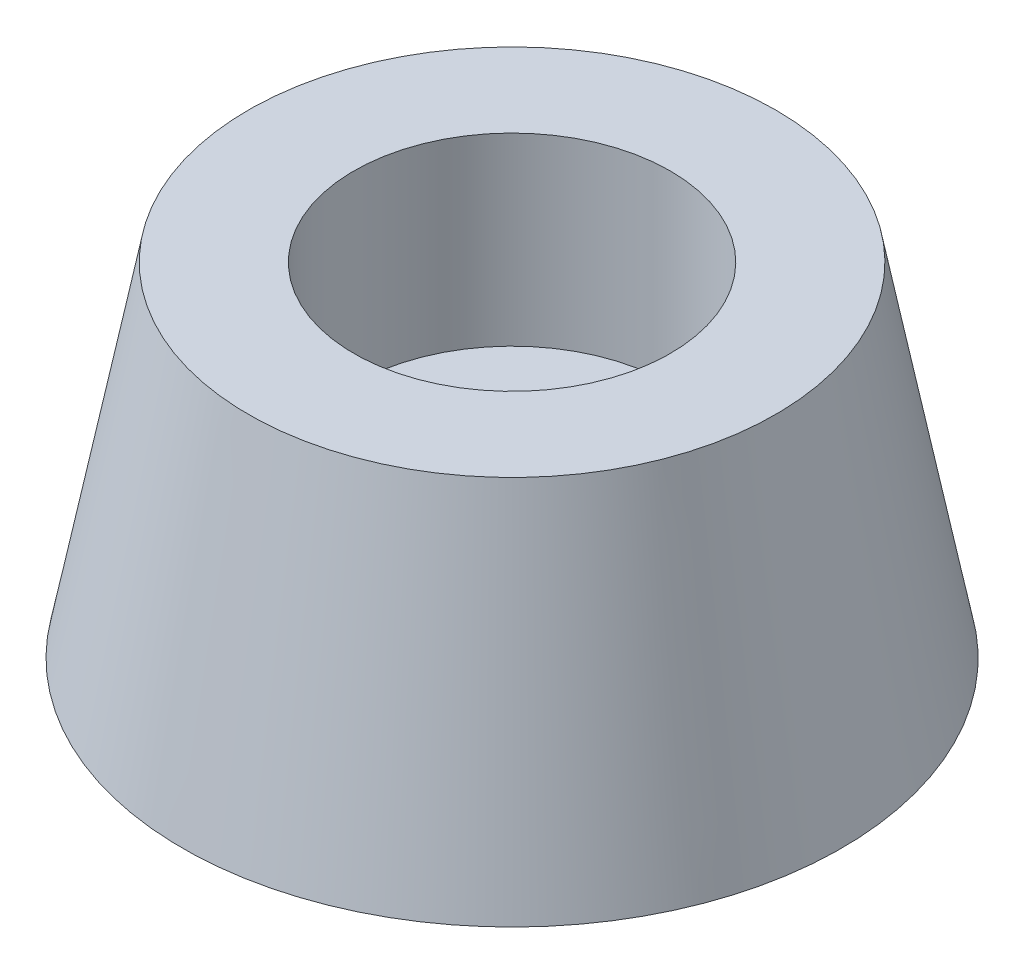
from build123d import *


with BuildPart() as part:
    # 草图1 → 旋转1 (revolve)
    with BuildSketch(Plane.XY):
        Polygon((-3, 0), (-12.5, 0), (-10, 13), (-6, 13), (-6, 6), (-3, 6), align=None)
    revolve(axis=Axis((0, 0, 0), (0, 1, 0)))


solid = part.part
